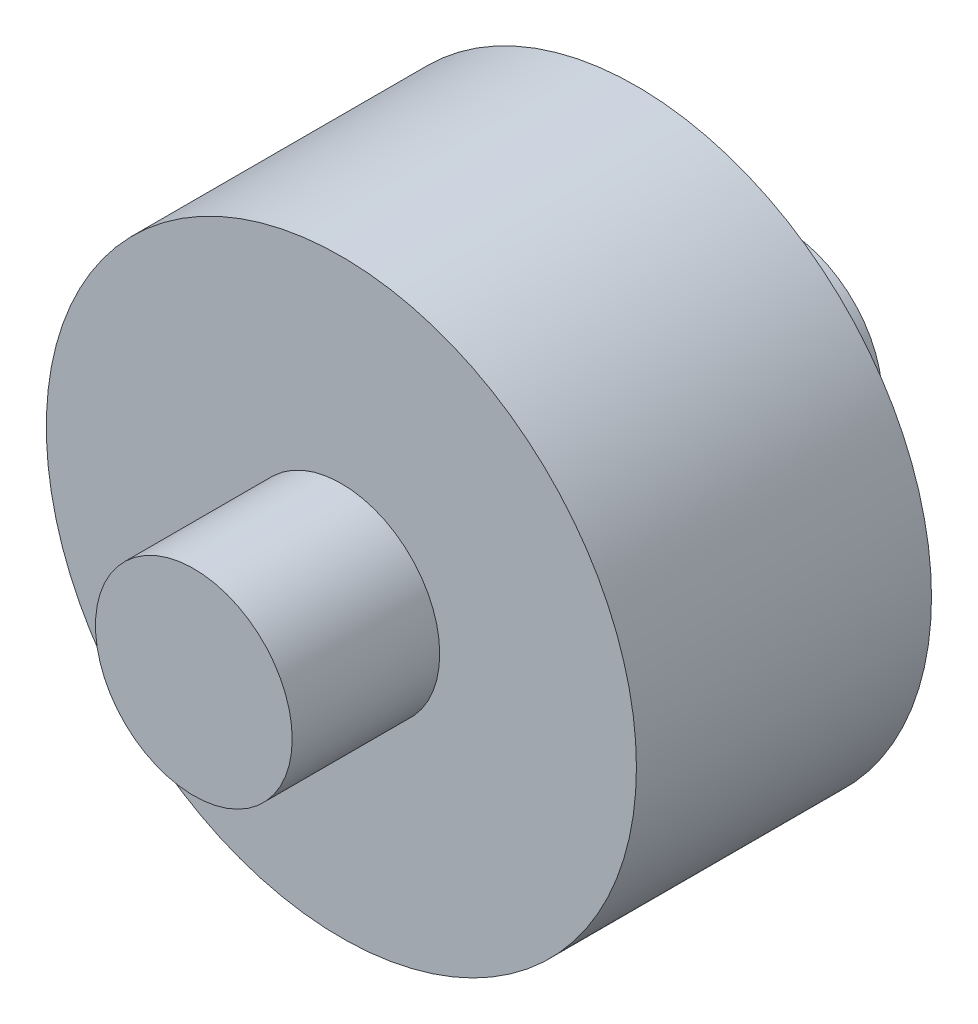
from build123d import *

# Parameters (mm, degrees)
SKETCH1_R           = 9.525
BOSS_EXTRUDE1_DEPTH = 4.7625
SKETCH2_R           = 3.175
BOSS_EXTRUDE2_DEPTH = 9.525
SKETCH3_R           = 3.175
CUT_EXTRUDE3_DEPTH  = 10.525


with BuildPart() as part:
    # Sketch1 → Boss-Extrude1 (new body, symmetric)
    with BuildSketch(Plane.XY):
        Circle(SKETCH1_R)
    extrude(amount=BOSS_EXTRUDE1_DEPTH, both=True)

    # Sketch2 → Boss-Extrude2 (add, symmetric)
    with BuildSketch(Plane.XY):
        Circle(SKETCH2_R)
    extrude(amount=BOSS_EXTRUDE2_DEPTH, both=True)

    # Sketch3 → Cut-Extrude3 (cut, through all)
    with BuildSketch(Plane(origin=(0, 0, 0), x_dir=(0, 0, -1), z_dir=(1, 0, 0))):
        Circle(SKETCH3_R)
    extrude(amount=-CUT_EXTRUDE3_DEPTH, mode=Mode.SUBTRACT)


solid = part.part
